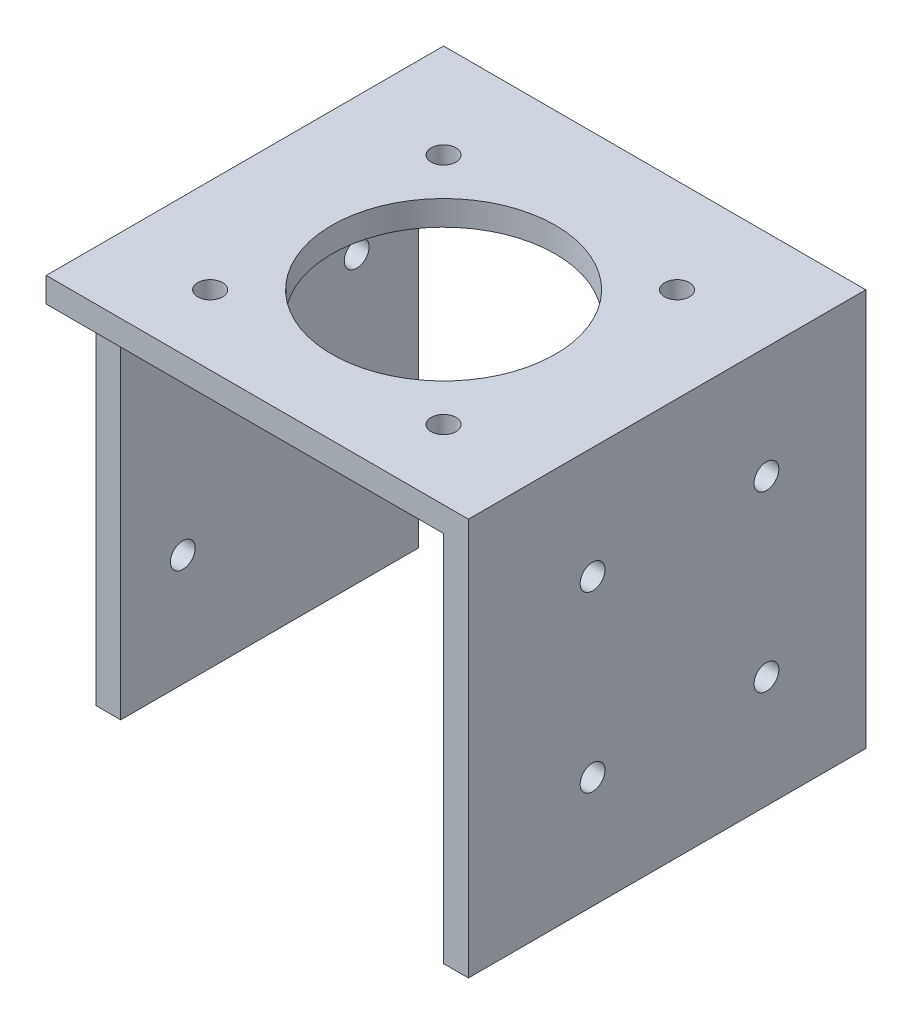
from build123d import *

# Parameters (mm, degrees)
SKETCH1_W           = 80
SKETCH1_H           = 80
BOSS_EXTRUDE1_DEPTH = 80
SKETCH2_W           = 75
SKETCH2_H           = 75
CUT_EXTRUDE1_DEPTH  = 75
SKETCH3_R           = 2.5
CUT_EXTRUDE2_DEPTH  = 50
SKETCH4_R           = 2.5
CUT_EXTRUDE3_DEPTH  = 50
SKETCH5_R           = 22.5
CUT_EXTRUDE4_DEPTH  = 50
SKETCH8_W           = 80
SKETCH8_H           = 80
BOSS_EXTRUDE2_DEPTH = 5
SKETCH9_R           = 2.5
CUT_EXTRUDE5_DEPTH  = 5
SKETCH10_W          = 5
SKETCH10_H          = 10
CUT_EXTRUDE6_DEPTH  = 75
SKETCH11_W          = 5
SKETCH11_H          = 75
CUT_EXTRUDE7_DEPTH  = 75


with BuildPart() as part:
    # Sketch1 → Boss-Extrude1 (new body)
    with BuildSketch(Plane.XY):
        Rectangle(SKETCH1_W, SKETCH1_H)
    extrude(amount=BOSS_EXTRUDE1_DEPTH)

    # Sketch2 → Cut-Extrude1 (cut)
    with BuildSketch(Plane.XY.offset(80)):
        with Locations((-2.5, -2.5)):
            Rectangle(SKETCH2_W, SKETCH2_H)
    extrude(amount=-CUT_EXTRUDE1_DEPTH, mode=Mode.SUBTRACT)

    # Sketch3 → Cut-Extrude2 (cut)
    with BuildSketch(Plane.ZY.offset(-35)):
        with Locations((55, -17.5)):
            Circle(SKETCH3_R)
        with Locations((20, -17.5)):
            Circle(SKETCH3_R)
        with Locations((20, 17.5)):
            Circle(SKETCH3_R)
        with Locations((55, 17.5)):
            Circle(SKETCH3_R)
    extrude(amount=-CUT_EXTRUDE2_DEPTH, mode=Mode.SUBTRACT)

    # Sketch4 → Cut-Extrude3 (cut)
    with BuildSketch(Plane.XZ.offset(-35)):
        with Locations((-26, 66)):
            Circle(SKETCH4_R)
        with Locations((21, 66)):
            Circle(SKETCH4_R)
        with Locations((-26, 19)):
            Circle(SKETCH4_R)
        with Locations((21, 19)):
            Circle(SKETCH4_R)
    extrude(amount=-CUT_EXTRUDE3_DEPTH, mode=Mode.SUBTRACT)

    # Sketch5 → Cut-Extrude4 (cut)
    with BuildSketch(Plane.XZ.offset(-35)):
        with Locations((-2.5, 42.5)):
            Circle(SKETCH5_R)
    extrude(amount=-CUT_EXTRUDE4_DEPTH, mode=Mode.SUBTRACT)

    # Sketch8 → Boss-Extrude2 (add)
    with BuildSketch(Plane.ZY.offset(40)):
        with Locations((40, 0)):
            Rectangle(SKETCH8_W, SKETCH8_H)
    extrude(amount=BOSS_EXTRUDE2_DEPTH)

    # Sketch9 → Cut-Extrude5 (cut)
    with BuildSketch(Plane.ZY.offset(45)):
        with Locations((22.5, 17.5)):
            Circle(SKETCH9_R)
        with Locations((57.5, 17.5)):
            Circle(SKETCH9_R)
        with Locations((22.5, -17.5)):
            Circle(SKETCH9_R)
        with Locations((57.5, -17.5)):
            Circle(SKETCH9_R)
    extrude(amount=-CUT_EXTRUDE5_DEPTH, mode=Mode.SUBTRACT)

    # Sketch10 → Cut-Extrude6 (cut)
    with BuildSketch(Plane.XZ.offset(40)):
        with Locations((-42.5, 75)):
            Rectangle(SKETCH10_W, SKETCH10_H)
        with Locations((-42.5, 5)):
            Rectangle(SKETCH10_W, SKETCH10_H)
    extrude(amount=-CUT_EXTRUDE6_DEPTH, mode=Mode.SUBTRACT)

    # Sketch11 → Cut-Extrude7 (cut)
    with BuildSketch(Plane.ZY.offset(40)):
        with Locations((2.5, -2.5)):
            Rectangle(SKETCH11_W, SKETCH11_H)
    extrude(amount=-CUT_EXTRUDE7_DEPTH, mode=Mode.SUBTRACT)


solid = part.part
